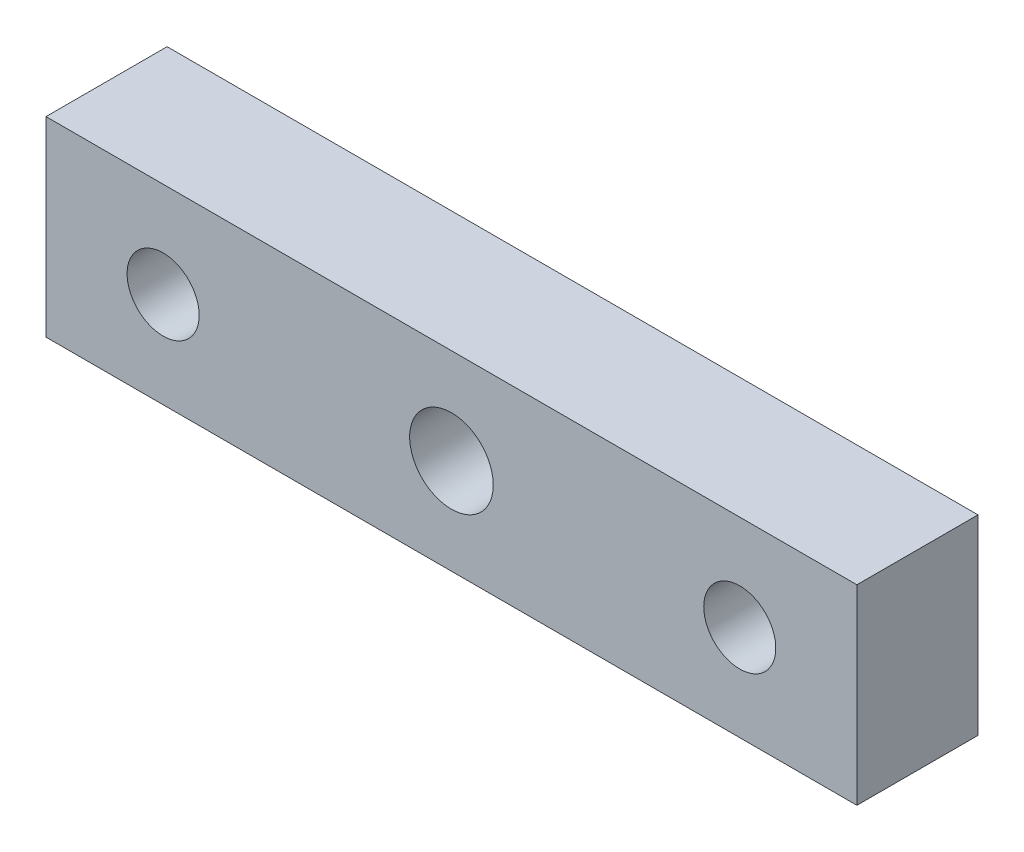
from build123d import *

# Parameters (mm, degrees)
SKETCH1_W           = 56.25
SKETCH1_H           = 13.25
SKETCH1_R           = 2.9
SKETCH1_R_2         = 2.5
BOSS_EXTRUDE1_DEPTH = 8.4


with BuildPart() as part:
    # Sketch1 → Boss-Extrude1 (new body)
    with BuildSketch(Plane.XY):
        Rectangle(SKETCH1_W, SKETCH1_H)
        Circle(SKETCH1_R, mode=Mode.SUBTRACT)
        with Locations((-20, 0)):
            Circle(SKETCH1_R_2, mode=Mode.SUBTRACT)
        with Locations((20, 0)):
            Circle(SKETCH1_R_2, mode=Mode.SUBTRACT)
    extrude(amount=BOSS_EXTRUDE1_DEPTH)


solid = part.part
